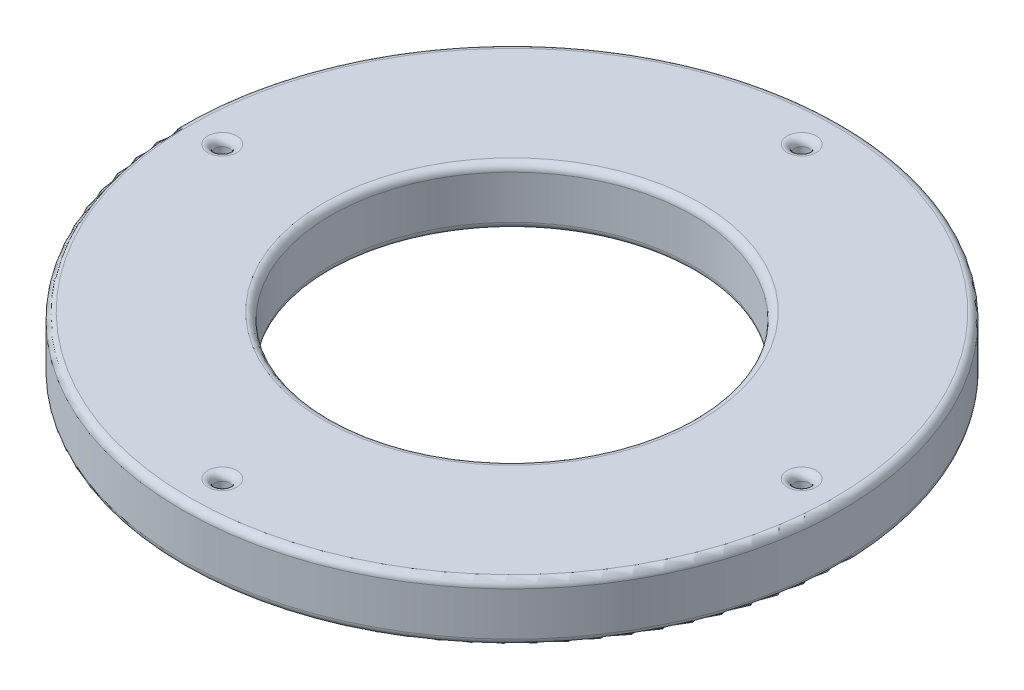
from build123d import *

# Parameters (mm, degrees)
ESQUISSE1_R        = 22.75
ESQUISSE1_R_2      = 12.5
ESQUISSE1_R_3      = 0.5
BOSS_EXTRU_1_DEPTH = 4
CONG_1_R           = 0.5
CONG_2_R           = 0.5


with BuildPart() as part:
    # Esquisse1 → Boss.-Extru.1 (new body)
    with BuildSketch(Plane(origin=(0, 0, 0), x_dir=(1, 0, 0), z_dir=(0, 1, 0))):
        Circle(ESQUISSE1_R)
        Circle(ESQUISSE1_R_2, mode=Mode.SUBTRACT)
        with Locations((20, 0)):
            Circle(ESQUISSE1_R_3, mode=Mode.SUBTRACT)
        with Locations((0, -20)):
            Circle(ESQUISSE1_R_3, mode=Mode.SUBTRACT)
        with Locations((-20, 0)):
            Circle(ESQUISSE1_R_3, mode=Mode.SUBTRACT)
        with Locations((0, 20)):
            Circle(ESQUISSE1_R_3, mode=Mode.SUBTRACT)
    extrude(amount=BOSS_EXTRU_1_DEPTH)

    # Congé1
    cong_1_edges = [part.edges().sort_by_distance(p)[0] for p in [
        (-22.75, 0, 0),
        (-22.75, 4, 0),
        (-12.5, 0, 0),
        (-12.5, 4, 0),
    ]]
    fillet(cong_1_edges, radius=CONG_1_R)

    # Congé2
    cong_2_edges = [part.edges().sort_by_distance(p)[0] for p in [
        (-0.5, 0, 20),
        (-0.5, 4, 20),
        (-20.5, 0, 0),
        (-20.5, 4, 0),
        (-0.5, 0, -20),
        (-0.5, 4, -20),
        (19.5, 0, 0),
        (19.5, 4, 0),
    ]]
    fillet(cong_2_edges, radius=CONG_2_R)


solid = part.part
